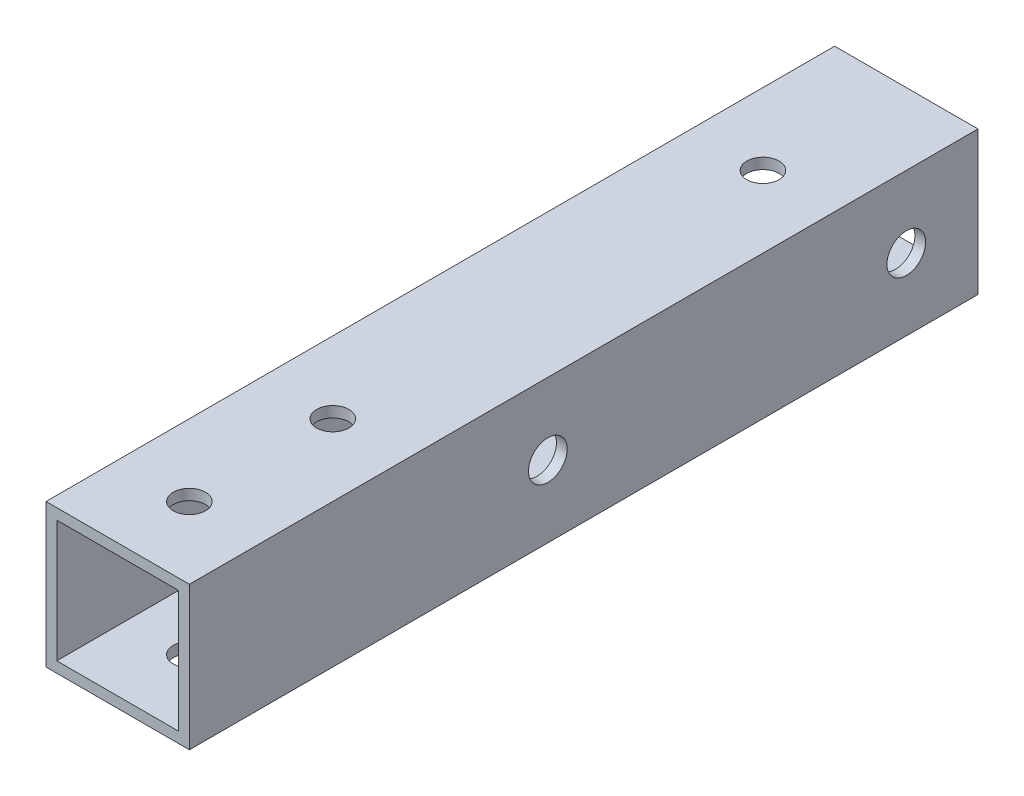
from build123d import *

# Parameters (mm, degrees)
SKETCH_1_W          = 20
SKETCH_1_H          = 20
SKETCH_1_W_2        = 17
SKETCH_1_H_2        = 17
EXTRUDE_1_DEPTH     = 110
SKETCH_2_R          = 2.7
CUT_EXTRUDE_1_DEPTH = 25
SKETCH_3_R          = 2.25
CUT_EXTRUDE_2_DEPTH = 20
SKETCH_5_R          = 5
CUT_EXTRUDE_4_DEPTH = 10
SKETCH_6_R          = 5
CUT_EXTRUDE_5_DEPTH = 10


with BuildPart() as part:
    # ｽｹｯﾁ1 → ﾎﾞｽ - 押し出し1 (new body)
    with BuildSketch(Plane.XY):
        Rectangle(SKETCH_1_W, SKETCH_1_H)
        Rectangle(SKETCH_1_W_2, SKETCH_1_H_2, mode=Mode.SUBTRACT)
    extrude(amount=EXTRUDE_1_DEPTH)

    # ｽｹｯﾁ2 → ｶｯﾄ - 押し出し1 (cut)
    with BuildSketch(Plane(origin=(10, 0, 0), x_dir=(0, 0, -1), z_dir=(1, 0, 0))):
        with Locations((-60, 0)):
            Circle(SKETCH_2_R)
        with Locations((-10, 0)):
            Circle(SKETCH_2_R)
    extrude(amount=-CUT_EXTRUDE_1_DEPTH, mode=Mode.SUBTRACT)

    # ｽｹｯﾁ3 → ｶｯﾄ - 押し出し2 (cut)
    with BuildSketch(Plane(origin=(0, 10, 0), x_dir=(1, 0, 0), z_dir=(0, 1, 0))):
        with Locations((0, -100)):
            Circle(SKETCH_3_R)
        with Locations((0, -80)):
            Circle(SKETCH_3_R)
        with Locations((0, -20)):
            Circle(SKETCH_3_R)
    extrude(amount=-CUT_EXTRUDE_2_DEPTH, mode=Mode.SUBTRACT)

    # ｽｹｯﾁ5 → ｶｯﾄ - 押し出し4 (cut)
    with BuildSketch(Plane(origin=(0, -10, 0), x_dir=(-1, 0, 0), z_dir=(0, -1, 0))):
        with Locations((0, -20)):
            Circle(SKETCH_5_R)
    extrude(amount=-CUT_EXTRUDE_4_DEPTH, mode=Mode.SUBTRACT)

    # ｽｹｯﾁ6 → ｶｯﾄ - 押し出し5 (cut)
    with BuildSketch(Plane.ZY.offset(10)):
        with Locations((10, 0)):
            Circle(SKETCH_6_R)
        with Locations((60, 0)):
            Circle(SKETCH_6_R)
    extrude(amount=-CUT_EXTRUDE_5_DEPTH, mode=Mode.SUBTRACT)


solid = part.part
